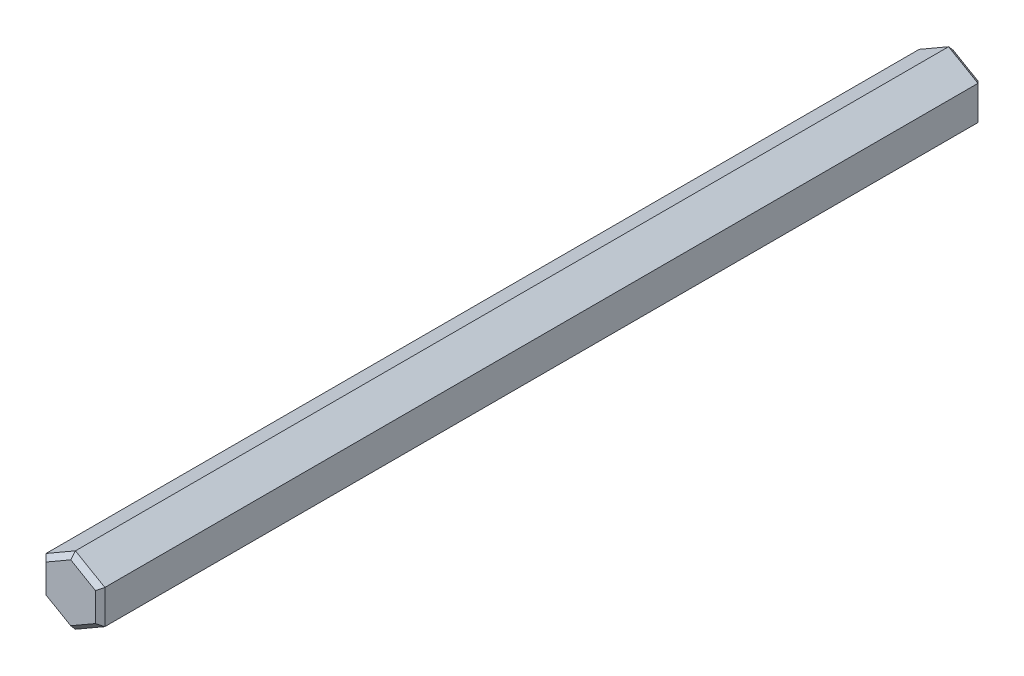
from build123d import *

# Parameters (mm, degrees)
BOSS_EXTRUDE1_DEPTH = 75
CHAMFER1_SIZE       = 0.4


with BuildPart() as part:
    # Sketch1 → Boss-Extrude1 (new body)
    with BuildSketch(Plane.XY.offset(75)):
        Polygon((0, -2.886751346), (2.5, -1.443375673), (2.5, 1.443375673), (0, 2.886751346), (-2.5, 1.443375673), (-2.5, -1.443375673), align=None)
    extrude(amount=-BOSS_EXTRUDE1_DEPTH)

    # Chamfer1
    chamfer1_edges = [part.edges().sort_by_distance(p)[0] for p in [
        (2.5, 0, 0),
        (1.25, 2.165063509, 0),
        (-1.25, 2.165063509, 0),
        (-2.5, 0, 0),
        (-1.25, -2.165063509, 0),
        (-2.5, 0, 75),
        (-1.25, 2.165063509, 75),
        (1.25, 2.165063509, 75),
        (1.25, -2.165063509, 0),
        (2.5, 0, 75),
        (1.25, -2.165063509, 75),
        (-1.25, -2.165063509, 75),
    ]]
    chamfer(chamfer1_edges, length=CHAMFER1_SIZE)


solid = part.part
